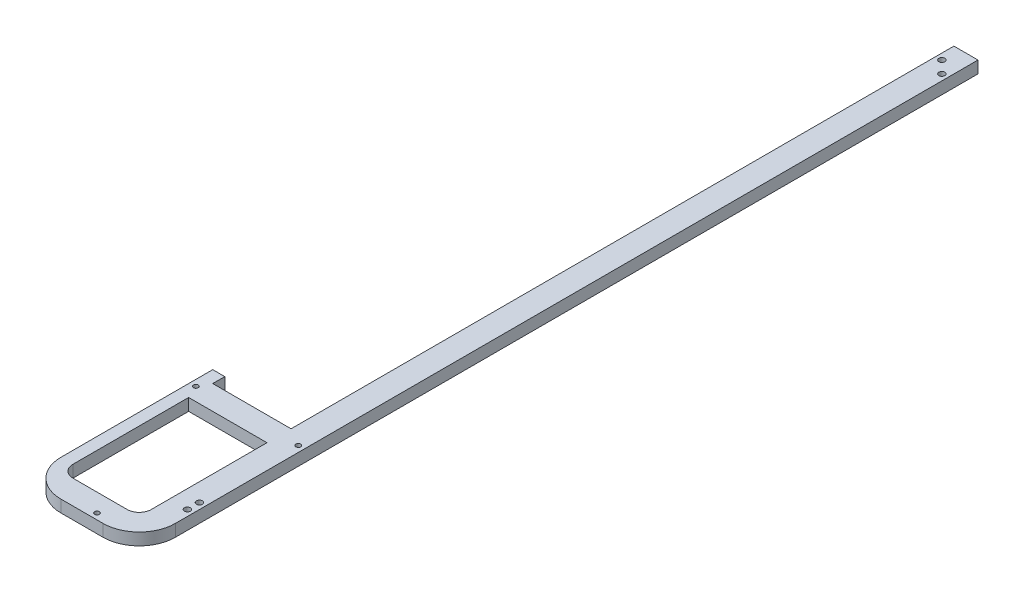
from build123d import *

# Parameters (mm, degrees)
BOSS_EXTRUDE1_DEPTH = 10
FILLET2_R           = 30
SKETCH2_R           = 2
CUT_EXTRUDE1_DEPTH  = 10
SKETCH3_R           = 2.5
CUT_EXTRUDE2_DEPTH  = 10
SKETCH4_R           = 2.5
CUT_EXTRUDE3_DEPTH  = 11
SKETCH5_W           = 65
SKETCH5_H           = 106
CUT_EXTRUDE4_DEPTH  = 11
FILLET3_R           = 10


with BuildPart() as part:
    # Sketch1 → Boss-Extrude1 (new body)
    with BuildSketch(Plane(origin=(0, 0, 0), x_dir=(1, 0, 0), z_dir=(0, 1, 0))):
        Polygon((-47.5, 86), (-47.5, -70), (47.5, -70), (47.5, 626), (27.5, 626), (27.5, 76), (-37.5, 76), (-37.5, 86), align=None)
    extrude(amount=BOSS_EXTRUDE1_DEPTH)

    # Fillet2
    fillet2_edges = [part.edges().sort_by_distance(p)[0] for p in [
        (47.5, 5, 70),
        (-47.5, 5, 70),
    ]]
    fillet(fillet2_edges, radius=FILLET2_R)

    # Sketch2 → Cut-Extrude1 (cut)
    with BuildSketch(Plane(origin=(0, 10, 0), x_dir=(1, 0, 0), z_dir=(0, 1, 0))):
        with Locations((-42.5, 67)):
            Circle(SKETCH2_R)
        with Locations((42.5, 67)):
            Circle(SKETCH2_R)
        with Locations((7.5, -65)):
            Circle(SKETCH2_R)
    extrude(amount=-CUT_EXTRUDE1_DEPTH, mode=Mode.SUBTRACT)

    # Sketch3 → Cut-Extrude2 (cut)
    with BuildSketch(Plane(origin=(0, 10, 0), x_dir=(1, 0, 0), z_dir=(0, 1, 0))):
        with Locations((42.5, 601)):
            Circle(SKETCH3_R)
        with Locations((32.5, 611)):
            Circle(SKETCH3_R)
    extrude(amount=-CUT_EXTRUDE2_DEPTH, mode=Mode.SUBTRACT)

    # Sketch4 → Cut-Extrude3 (cut, through all)
    with BuildSketch(Plane(origin=(0, 10, 0), x_dir=(1, 0, 0), z_dir=(0, 1, 0))):
        with Locations((42.5, -25)):
            Circle(SKETCH4_R)
        with Locations((42.5, -15)):
            Circle(SKETCH4_R)
    extrude(amount=-CUT_EXTRUDE3_DEPTH, mode=Mode.SUBTRACT)

    # Sketch5 → Cut-Extrude4 (cut, through all)
    with BuildSketch(Plane(origin=(0, 10, 0), x_dir=(1, 0, 0), z_dir=(0, 1, 0))):
        with Locations((-5, 3)):
            Rectangle(SKETCH5_W, SKETCH5_H)
    extrude(amount=-CUT_EXTRUDE4_DEPTH, mode=Mode.SUBTRACT)

    # Fillet3
    fillet3_edges = [part.edges().sort_by_distance(p)[0] for p in [
        (-37.5, 5, 50),
        (27.5, 5, 50),
    ]]
    fillet(fillet3_edges, radius=FILLET3_R)


solid = part.part
